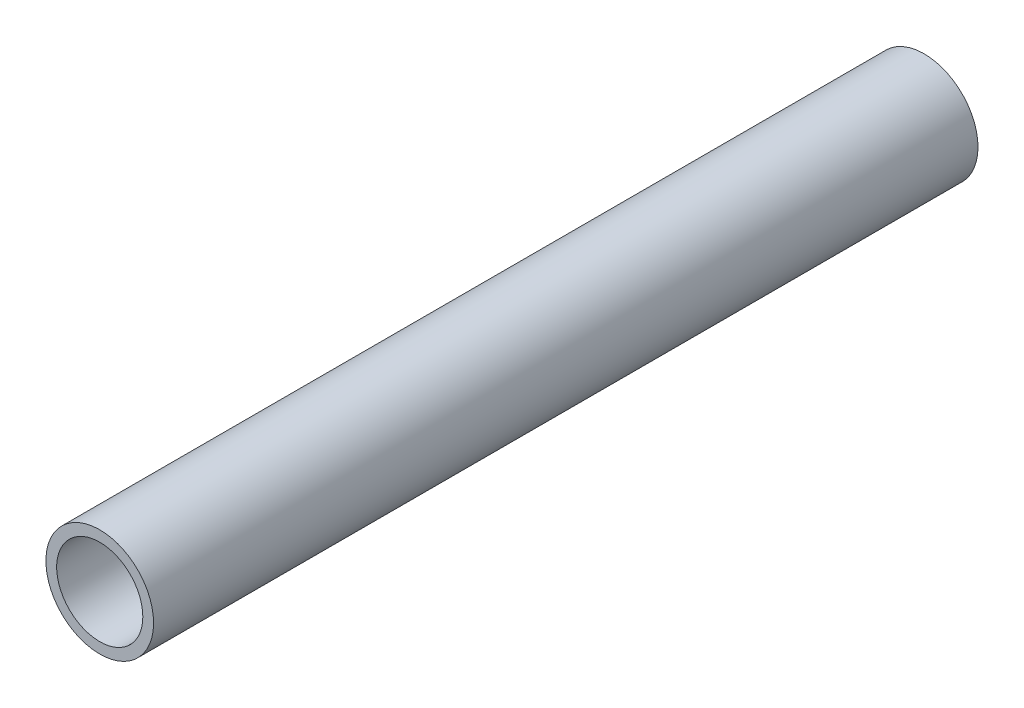
from build123d import *

# Parameters (mm, degrees)
SKETCH1_R           = 1.25
SKETCH1_R_2         = 1
BOSS_EXTRUDE1_DEPTH = 19.14


with BuildPart() as part:
    # Sketch1 → Boss-Extrude1 (new body)
    with BuildSketch(Plane.XY):
        Circle(SKETCH1_R)
        Circle(SKETCH1_R_2, mode=Mode.SUBTRACT)
    extrude(amount=BOSS_EXTRUDE1_DEPTH)


solid = part.part
